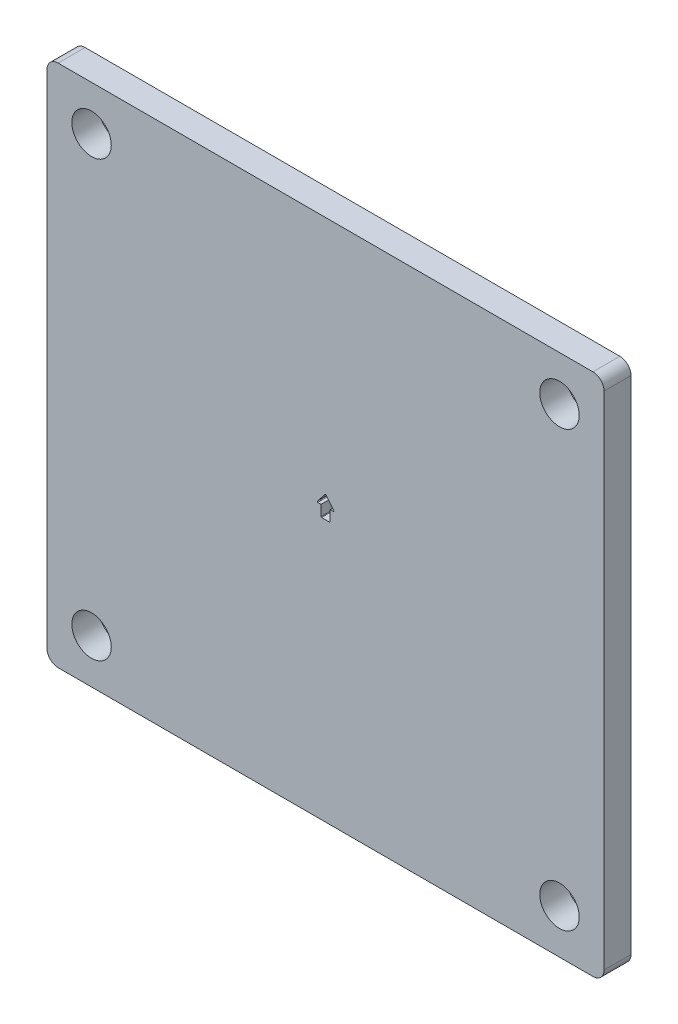
from build123d import *

# Parameters (mm, degrees)
SKETCH1_W             = 63.5
SKETCH1_H             = 59.69
BOSS_EXTRUDE1_DEPTH   = 3.0734
FILLET1_R             = 1.27
F_8_CLEARANCE_HOLE1_D = 4.4958
CUT_EXTRUDE1_DEPTH    = 4.0734
FILLET2_R             = 0.0635


with BuildPart() as part:
    # Sketch1 → Boss-Extrude1 (new body)
    with BuildSketch(Plane.XY):
        with Locations((31.75, 29.845)):
            Rectangle(SKETCH1_W, SKETCH1_H)
    extrude(amount=BOSS_EXTRUDE1_DEPTH)

    # Fillet1
    fillet1_edges = [part.edges().sort_by_distance(p)[0] for p in [
        (0, 59.69, 1.5367),
        (63.5, 59.69, 1.5367),
        (63.5, 0, 1.5367),
        (0, 0, 1.5367),
    ]]
    fillet(fillet1_edges, radius=FILLET1_R)

    # #8 Clearance Hole1 (through all)
    with Locations(Plane.XY.offset(3.0734)):
        with Locations((5.08, 54.61), (58.42, 54.61), (58.42, 5.08), (5.08, 5.08)):
            Hole(F_8_CLEARANCE_HOLE1_D / 2)

    # Sketch7 → Cut-Extrude1 (cut, through all)
    with BuildSketch(Plane.XY.offset(3.0734)):
        Polygon((31.242, 29.845), (31.242, 31.115), (30.734, 31.115), (31.75, 32.385), (32.766, 31.115), (32.258, 31.115), (32.258, 29.845), align=None)
    extrude(amount=-CUT_EXTRUDE1_DEPTH, mode=Mode.SUBTRACT)

    # Fillet2
    fillet2_edges = [part.edges().sort_by_distance(p)[0] for p in [
        (32.258, 29.845, 1.5367),
        (31.242, 29.845, 1.5367),
        (30.734, 31.115, 1.5367),
        (31.75, 32.385, 1.5367),
        (32.766, 31.115, 1.5367),
        (32.258, 31.115, 1.5367),
    ]]
    fillet(fillet2_edges, radius=FILLET2_R)


solid = part.part
